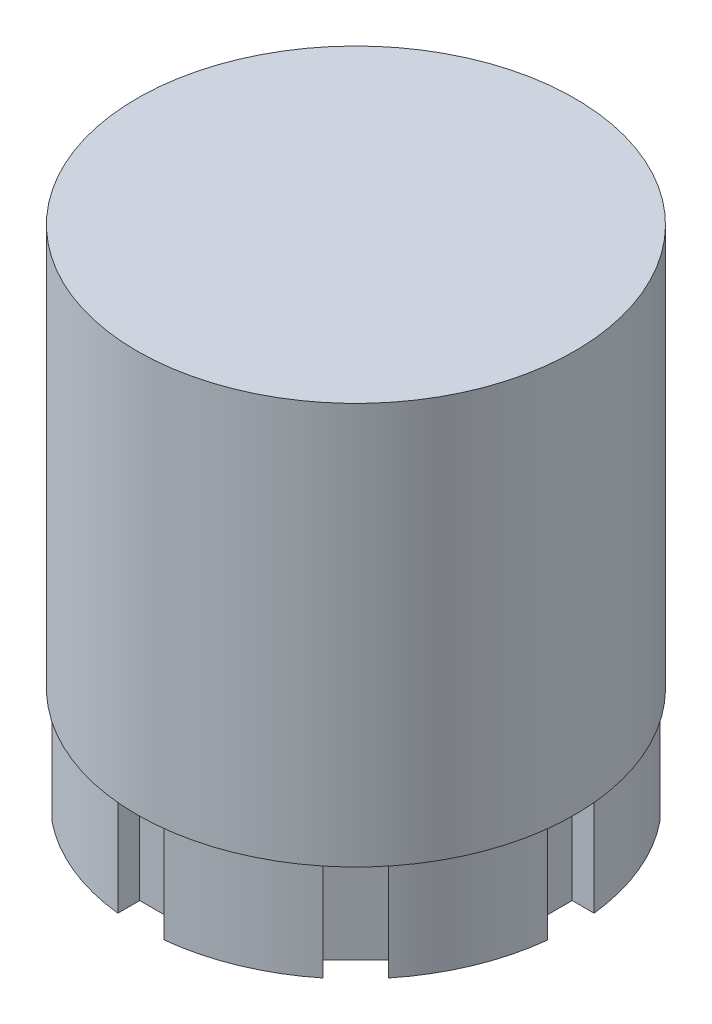
from build123d import *

# Parameters (mm, degrees)
SKETCH1_R           = 22.5
BOSS_EXTRUDE1_DEPTH = 20.6375
SKETCH3_R           = 22.225
BOSS_EXTRUDE2_DEPTH = 10.16
SKETCH4_W           = 4.7625
SKETCH4_H           = 4.7625
CUT_EXTRUDE2_DEPTH  = 10.16
CIRPATTERN2_COUNT   = 8


with BuildPart() as part:
    # Sketch1 → Boss-Extrude1 (new body, symmetric)
    with BuildSketch(Plane(origin=(0, 0, 0), x_dir=(1, 0, 0), z_dir=(0, 1, 0))):
        Circle(SKETCH1_R)
    extrude(amount=BOSS_EXTRUDE1_DEPTH, both=True)

    # Sketch3 → Boss-Extrude2 (add)
    with BuildSketch(Plane(origin=(0, -20.6375, 0), x_dir=(-1, 0, 0), z_dir=(0, -1, 0))):
        Circle(SKETCH3_R)
    extrude(amount=BOSS_EXTRUDE2_DEPTH)

    # Sketch4 → Cut-Extrude2 (cut)
    with BuildSketch(Plane.XZ.offset(30.7975)):
        with Locations((0, 22.225)):
            Rectangle(SKETCH4_W, SKETCH4_H)
    cut_extrude2 = extrude(amount=-CUT_EXTRUDE2_DEPTH, mode=Mode.SUBTRACT)

    # CirPattern2: Cut-Extrude2 ×8 about axis
    cirpattern2_axis = Axis((0, 0, 0), (0, 1, 0))
    for i in range(1, CIRPATTERN2_COUNT):
        add(cut_extrude2.rotate(cirpattern2_axis, i * 360 / CIRPATTERN2_COUNT), mode=Mode.SUBTRACT)


solid = part.part
